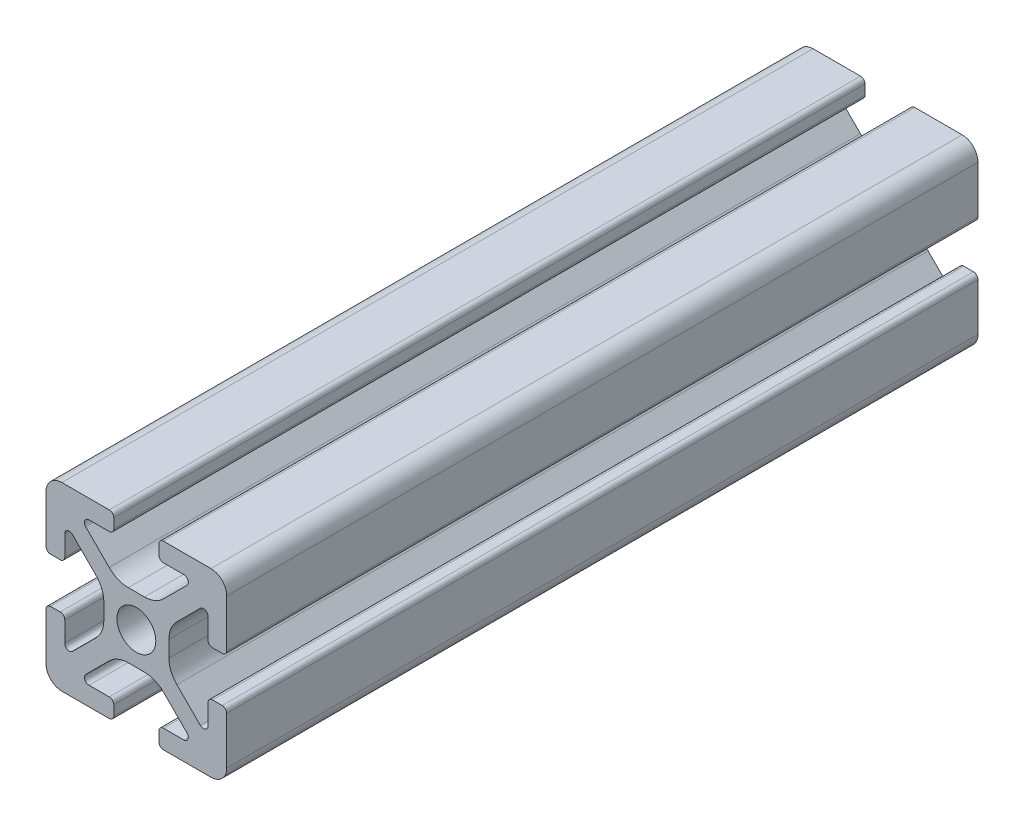
from build123d import *

# Parameters (mm, degrees)
BOSS_EXTRUDE1_DEPTH = 41.57


with BuildPart() as part:
    # Sketch4 → Boss-Extrude1 (new body, symmetric)
    with BuildSketch(Plane.XY):
        with BuildLine():
            Line((3, -10), (8.25, -10))
            ThreePointArc((8.25, -10), (9.487436867, -9.487436867), (10, -8.25))
            Line((10, -8.25), (10, -3))
            ThreePointArc((10, -3), (9.853553391, -2.646446609), (9.5, -2.5))
            Line((9.5, -2.5), (8.424621202, -2.5))
            ThreePointArc((8.424621202, -2.5), (8.071067812, -2.646446609), (7.924621202, -3))
            Line((7.924621202, -3), (7.924621202, -5.25))
            ThreePointArc((7.924621202, -5.25), (7.615962919, -5.711939766), (7.071067812, -5.603553391))
            Line((7.071067812, -5.603553391), (4.478679656, -3.011165235))
            ThreePointArc((4.478679656, -3.011165235), (3.828361402, -2.037895189), (3.6, -0.889844892))
            Line((3.6, -0.889844892), (3.6, 0))
            Line((3.6, 0), (2.15, 0))
            ThreePointArc((2.15, 0), (1.52027958, -1.52027958), (0, -2.15))
            Line((0, -2.15), (0, -3.6))
            Line((0, -3.6), (0.889844892, -3.6))
            ThreePointArc((0.889844892, -3.6), (2.037895189, -3.828361402), (3.011165235, -4.478679656))
            Line((3.011165235, -4.478679656), (5.603553391, -7.071067812))
            ThreePointArc((5.603553391, -7.071067812), (5.711939766, -7.615962919), (5.25, -7.924621202))
            Line((5.25, -7.924621202), (3, -7.924621202))
            ThreePointArc((3, -7.924621202), (2.646446609, -8.071067812), (2.5, -8.424621202))
            Line((2.5, -8.424621202), (2.5, -9.5))
            ThreePointArc((2.5, -9.5), (2.646446609, -9.853553391), (3, -10))
        make_face()
    extrude(amount=BOSS_EXTRUDE1_DEPTH, both=True)

    # Mirror1: part across plane


with BuildPart() as part_1:
    add(part.part)
    add(part.part.mirror(Plane(origin=(0, 0, 0), x_dir=(0, 0, 1), z_dir=(1, 0, 0))))

    # Mirror2: part across plane


with BuildPart() as part_2:
    add(part_1.part)
    add(part_1.part.mirror(Plane.ZX))


solid = part_2.part
